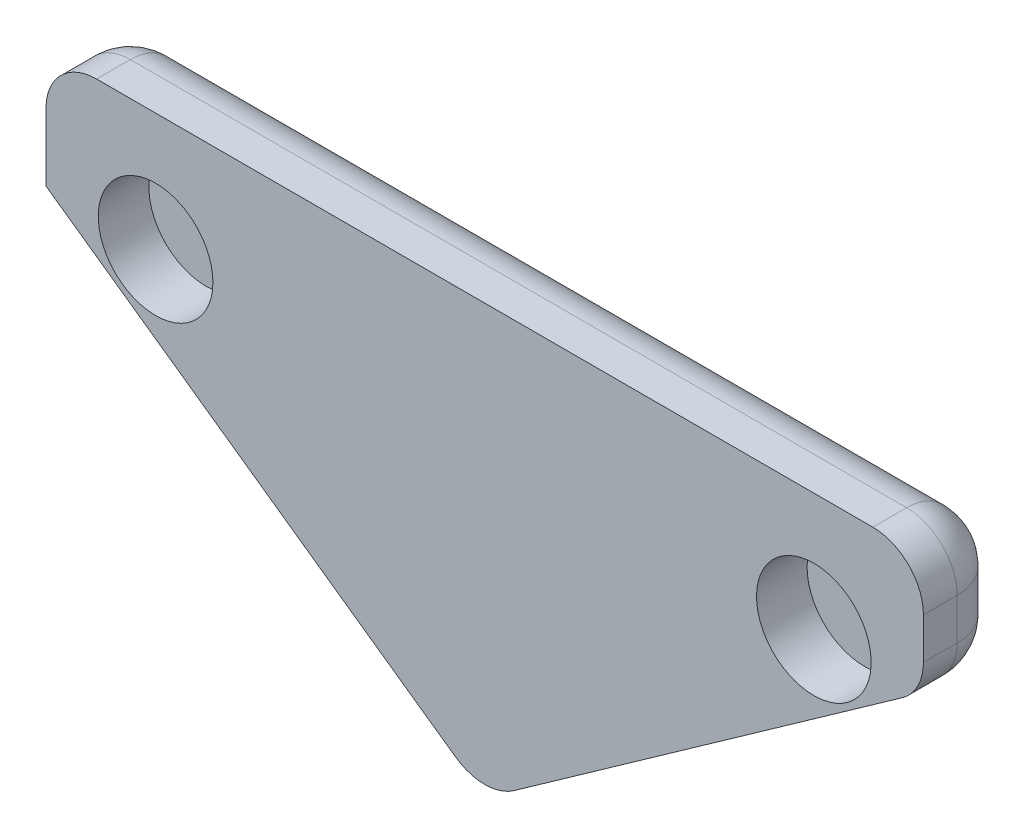
from build123d import *

# Parameters (mm, degrees)
BOSS_EXTRUDE1_DEPTH = 2.5
SKETCH2_R           = 1.7
CUT_EXTRUDE1_DEPTH  = 1.5
FILLET1_R           = 1.5


with BuildPart() as part:
    # Sketch1 → Boss-Extrude1 (new body)
    with BuildSketch(Plane.XY):
        Polygon((-7.56419618, 12.7), (-7.56419618, 9.2), (5.44580382, 0), (5.44580382, 12.7), align=None)
    extrude(amount=BOSS_EXTRUDE1_DEPTH)

    # Sketch2 → Cut-Extrude1 (cut)
    with BuildSketch(Plane.XY.offset(2.5)):
        with Locations((-4.31419618, 9.2)):
            Circle(SKETCH2_R)
    extrude(amount=-CUT_EXTRUDE1_DEPTH, mode=Mode.SUBTRACT)

    # Mirror2: part across plane


with BuildPart() as part_1:
    add(part.part)
    add(part.part.mirror(Plane(origin=(5.44580382, 0, 2.5), x_dir=(0, 0, 1), z_dir=(-1, 0, 0))))

    # Fillet1
    fillet1_edges = [part_1.edges().sort_by_distance(p)[0] for p in [
        (18.45580382, 12.7, 1.25),
        (18.45580382, 9.2, 1.25),
        (5.44580382, 0, 1.25),
        (18.45580382, 10.95, 0),
        (11.95080382, 4.6, 0),
        (-1.05919618, 4.6, 0),
        (-7.56419618, 10.95, 0),
        (5.44580382, 12.7, 0),
        (-7.56419618, 12.7, 1.25),
    ]]
    fillet(fillet1_edges, radius=FILLET1_R)


solid = part_1.part
